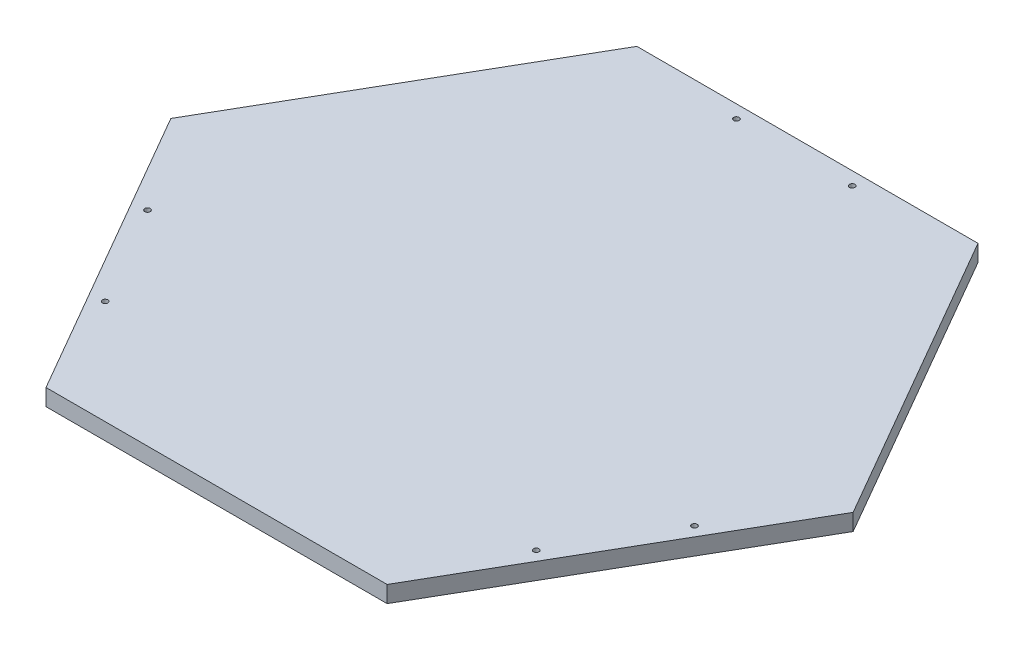
from build123d import *

# Parameters (mm, degrees)
BOSS_EXTRUDE1_DEPTH         = 12.7
TAP_DRILL_FOR_M5X0_8_TAP1_D = 4.2


with BuildPart() as part:
    # Sketch1 → Boss-Extrude1 (new body)
    with BuildSketch(Plane(origin=(0, 0, 0), x_dir=(1, 0, 0), z_dir=(0, 1, 0))):
        Polygon((130.207581625, -225.526146906), (260.415163251, 0), (130.207581625, 225.526146906), (-130.207581625, 225.526146906), (-260.415163251, 0), (-130.207581625, -225.526146906), align=None)
    extrude(amount=BOSS_EXTRUDE1_DEPTH)

    # Tap Drill for M5x0.8 Tap1 (through all)
    with Locations(Plane(origin=(0, 12.7, 0), x_dir=(1, 0, 0), z_dir=(0, 1, 0))):
        with Locations((-44.207581625, 215.526146906), (44.207581625, 215.526146906), (-208.754909213, -69.478184725), (-164.547327587, -146.04796218), (164.547327587, -146.04796218), (208.754909213, -69.478184725)):
            Hole(TAP_DRILL_FOR_M5X0_8_TAP1_D / 2)


solid = part.part
